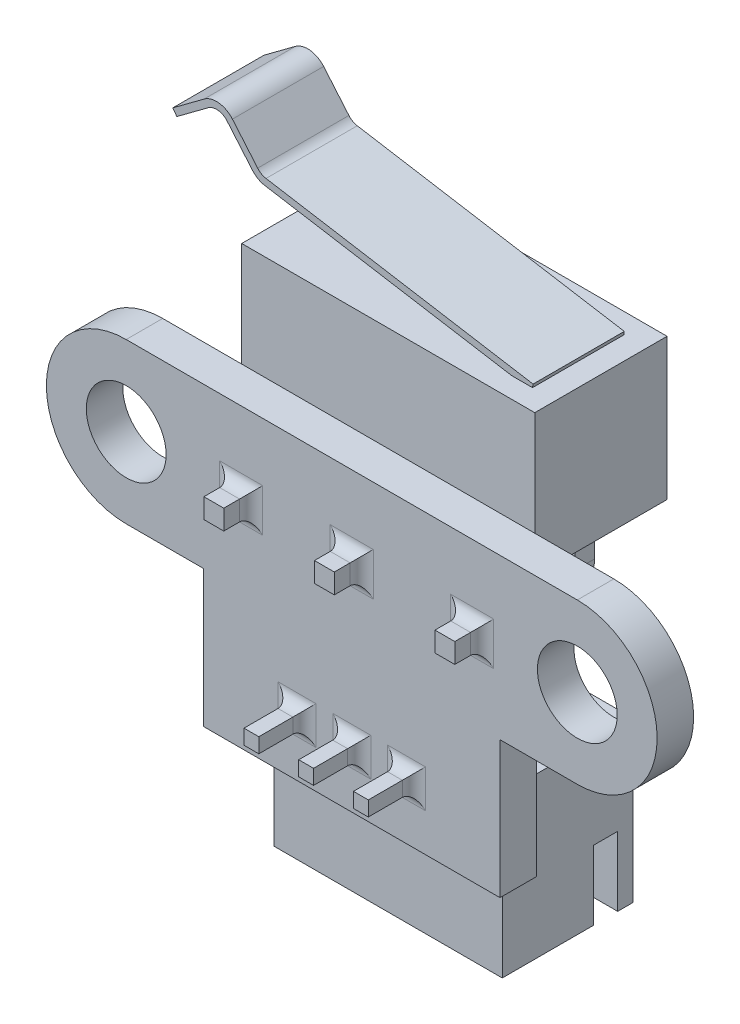
from build123d import *

# Parameters (mm, degrees)
SKETCH1_R           = 1.75
BOSS_EXTRUDE1_DEPTH = 1.6
SKETCH2_W           = 12.85
SKETCH2_H           = 6.2
BOSS_EXTRUDE2_DEPTH = 5.8
BOSS_EXTRUDE3_DEPTH = 2
SKETCH4_W           = 0.87
SKETCH4_H           = 0.87
SKETCH6_W           = 10
SKETCH6_H           = 7
BOSS_EXTRUDE4_DEPTH = 5.73
SKETCH7_W           = 8.66
SKETCH7_H           = 4.39
CUT_EXTRUDE1_DEPTH  = 5.35
SKETCH8_W           = 1.64
SKETCH8_H           = 0.67
CUT_EXTRUDE2_DEPTH  = 3.86
SKETCH9_W           = 0.67
SKETCH9_H           = 1.07
CUT_EXTRUDE3_DEPTH  = 3.04
SKETCH11_W          = 0.65
SKETCH11_H          = 0.65
FILLET1_R           = 0.508


with BuildPart() as part:
    # Sketch1 → Boss-Extrude1 (new body)
    with BuildSketch(Plane.XY):
        with BuildLine():
            Line((-9.890000015, 3.499999985), (9.890000015, 3.499999985))
            ThreePointArc((9.890000015, 3.499999985), (13.39, 0), (9.890000015, -3.499999985))
            Line((9.890000015, -3.499999985), (6.5, -3.499999985))
            Line((6.5, -3.499999985), (6.5, -9.500000015))
            Line((6.5, -9.500000015), (-6.5, -9.500000015))
            Line((-6.5, -9.500000015), (-6.5, -3.499999985))
            Line((-6.5, -3.499999985), (-9.890000015, -3.499999985))
            ThreePointArc((-9.890000015, -3.499999985), (-13.39, 0), (-9.890000015, 3.499999985))
        make_face()
        with Locations((-9.890000015, 0)):
            Circle(SKETCH1_R, mode=Mode.SUBTRACT)
        with Locations((9.890000015, 0)):
            Circle(SKETCH1_R, mode=Mode.SUBTRACT)
    extrude(amount=BOSS_EXTRUDE1_DEPTH)

    # Sketch2 → Boss-Extrude2 (add)
    with BuildSketch(Plane(origin=(0, 0, 0), x_dir=(-1, 0, 0), z_dir=(0, 0, -1))):
        with Locations((0, 4.979999985)):
            Rectangle(SKETCH2_W, SKETCH2_H)
    extrude(amount=BOSS_EXTRUDE2_DEPTH)

    # Sketch3 → Boss-Extrude3 (add, symmetric)
    with BuildSketch(Plane.XY.offset(-2.9)):
        with BuildLine():
            Line((5.449691358, 8.227953818), (-6.259057602, 10.18197492))
            ThreePointArc((-6.259057602, 10.18197492), (-6.460661712, 10.25352545), (-6.625323786, 10.390090807))
            Line((-6.625323786, 10.390090807), (-7.732620651, 11.697470228))
            ThreePointArc((-7.732620651, 11.697470228), (-8.324478366, 12.014086654), (-8.972711282, 11.839915469))
            Line((-8.972711282, 11.839915469), (-10.347606141, 10.817657467))
            Line((-10.347606141, 10.817657467), (-10.168606555, 10.576910404))
            Line((-10.168606555, 10.576910404), (-8.793711695, 11.599168407))
            ThreePointArc((-8.793711695, 11.599168407), (-8.358713291, 11.716046438), (-7.961545614, 11.503580153))
            Line((-7.961545614, 11.503580153), (-6.854248749, 10.196200732))
            ThreePointArc((-6.854248749, 10.196200732), (-6.608869972, 9.992691572), (-6.308440318, 9.886067253))
            Line((-6.308440318, 9.886067253), (5.400308642, 7.932046152))
            Line((5.400308642, 7.932046152), (5.449691358, 8.227953818))
        make_face()
    extrude(amount=BOSS_EXTRUDE3_DEPTH, both=True)

    # Sweep3: sweep along a path in Sketch5
    with BuildLine(Plane(origin=(0, 0, 0), x_dir=(0, 0, -1), z_dir=(1, 0, 0))) as sweep3_path:
        Line((2.9, 1.879999985), (2.9, 0.508))
        ThreePointArc((2.9, 0.508), (2.751210245, 0.148789755), (2.392, 0))
        Line((2.392, 0), (-2.8, 0))
    # Sketch4 → Sweep3 (sweep)
    with BuildSketch(Plane.XZ.offset(-1.879999985)):
        with Locations((-4.8475, -2.9)):
            Rectangle(SKETCH4_W, SKETCH4_H)
        with Locations((0, -2.9)):
            Rectangle(SKETCH4_W, SKETCH4_H)
        with Locations((5.2825, -2.9)):
            Rectangle(SKETCH4_W, SKETCH4_H)
    sweep(path=sweep3_path.line)

    # Sketch6 → Boss-Extrude4 (add)
    with BuildSketch(Plane(origin=(0, 0, 0), x_dir=(-1, 0, 0), z_dir=(0, 0, -1))):
        with Locations((0, -10.600000015)):
            Rectangle(SKETCH6_W, SKETCH6_H)
    extrude(amount=BOSS_EXTRUDE4_DEPTH)

    # Sketch7 → Cut-Extrude1 (cut)
    with BuildSketch(Plane.XZ.offset(14.100000015)):
        with Locations((0, -2.865)):
            Rectangle(SKETCH7_W, SKETCH7_H)
    extrude(amount=-CUT_EXTRUDE1_DEPTH, mode=Mode.SUBTRACT)

    # Sketch8 → Cut-Extrude2 (cut)
    with BuildSketch(Plane(origin=(0, -14.100000015, 0), x_dir=(-1, 0, 0), z_dir=(0, -1, 0))):
        with Locations((2.4, 5.395)):
            Rectangle(SKETCH8_W, SKETCH8_H)
        with Locations((-2.4, 5.395)):
            Rectangle(SKETCH8_W, SKETCH8_H)
    extrude(amount=-CUT_EXTRUDE2_DEPTH, mode=Mode.SUBTRACT)

    # Sketch9 → Cut-Extrude3 (cut)
    with BuildSketch(Plane.XZ.offset(14.100000015)):
        with Locations((-4.665, -4.525)):
            Rectangle(SKETCH9_W, SKETCH9_H)
        with Locations((4.665, -4.525)):
            Rectangle(SKETCH9_W, SKETCH9_H)
    extrude(amount=-CUT_EXTRUDE3_DEPTH, mode=Mode.SUBTRACT)

    # Sweep4: sweep along a path in Sketch10
    with BuildLine(Plane(origin=(0, 0, 0), x_dir=(0, 0, -1), z_dir=(1, 0, 0))) as sweep4_path:
        Line((3.43, -13.430000015), (3.43, -7.508000015))
        ThreePointArc((3.43, -7.508000015), (3.281210245, -7.14878977), (2.922, -7.000000015))
        Line((2.922, -7.000000015), (-3.6, -7.000000015))
    # Sketch11 → Sweep4 (sweep)
    with BuildSketch(Plane(origin=(0, -13.430000015, 0), x_dir=(1, 0, 0), z_dir=(0, 1, 0))):
        with Locations((-2.4, 3.43)):
            Rectangle(SKETCH11_W, SKETCH11_H)
        with Locations((0, 3.43)):
            Rectangle(SKETCH11_W, SKETCH11_H)
        with Locations((2.4, 3.43)):
            Rectangle(SKETCH11_W, SKETCH11_H)
    sweep(path=sweep4_path.line)

    # Fillet1
    fillet1_edges = [part.edges().sort_by_distance(p)[0] for p in [
        (0, 0.435, 1.6),
        (0.435, 0, 1.6),
        (0, -0.435, 1.6),
        (-0.435, 0, 1.6),
        (5.2825, 0.435, 1.6),
        (5.7175, 0, 1.6),
        (5.2825, -0.435, 1.6),
        (4.8475, 0, 1.6),
        (-2.4, -6.675000015, 1.6),
        (-2.4, -7.325000015, 1.6),
        (-2.725, -7.000000015, 1.6),
        (-2.075, -7.000000015, 1.6),
        (0, -6.675000015, 1.6),
        (0, -7.325000015, 1.6),
        (-0.325, -7.000000015, 1.6),
        (0.325, -7.000000015, 1.6),
        (2.4, -6.675000015, 1.6),
        (2.4, -7.325000015, 1.6),
        (2.075, -7.000000015, 1.6),
        (2.725, -7.000000015, 1.6),
        (-4.8475, 0.435, 1.6),
        (-4.4125, 0, 1.6),
        (-4.8475, -0.435, 1.6),
        (-5.2825, 0, 1.6),
    ]]
    fillet(fillet1_edges, radius=FILLET1_R)


solid = part.part
